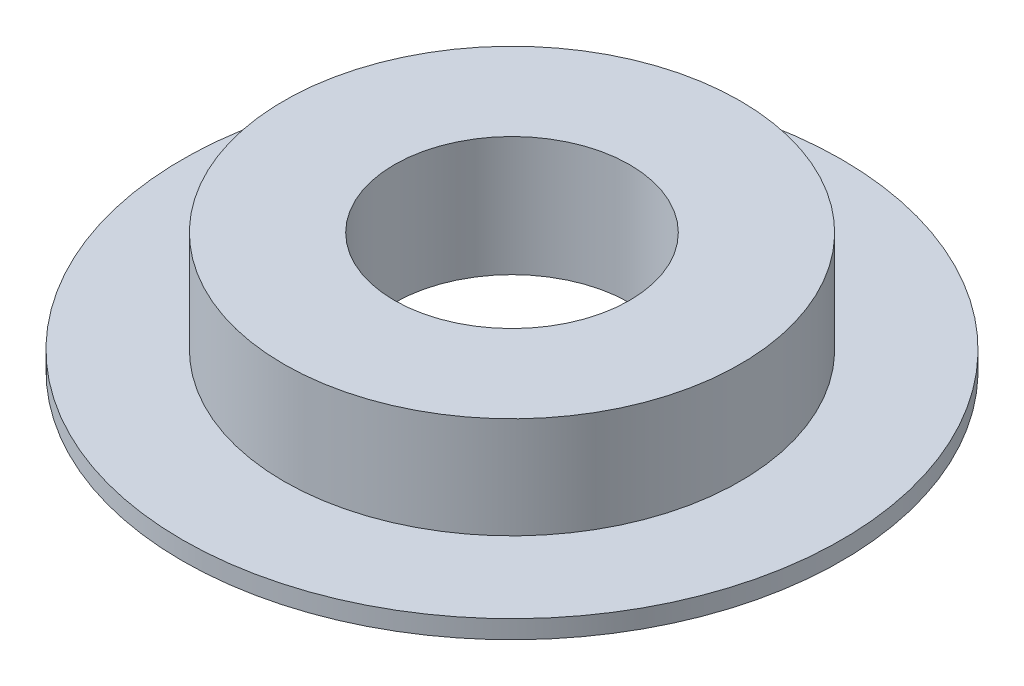
from build123d import *


with BuildPart() as part:
    # Croquis1 → Revolución1 (revolve)
    with BuildSketch(Plane.XY):
        Polygon((-45.12158728, 8.972889318), (-45.12158728, -2.827110682), (-66.02158728, -2.827110682), (-66.02158728, -1.027110682), (-56.02158728, -1.027110682), (-56.02158728, 8.972889318), align=None)
    revolve(axis=Axis((-33.52158728, 13.972889318, 0), (0, -1, 0)))


solid = part.part
